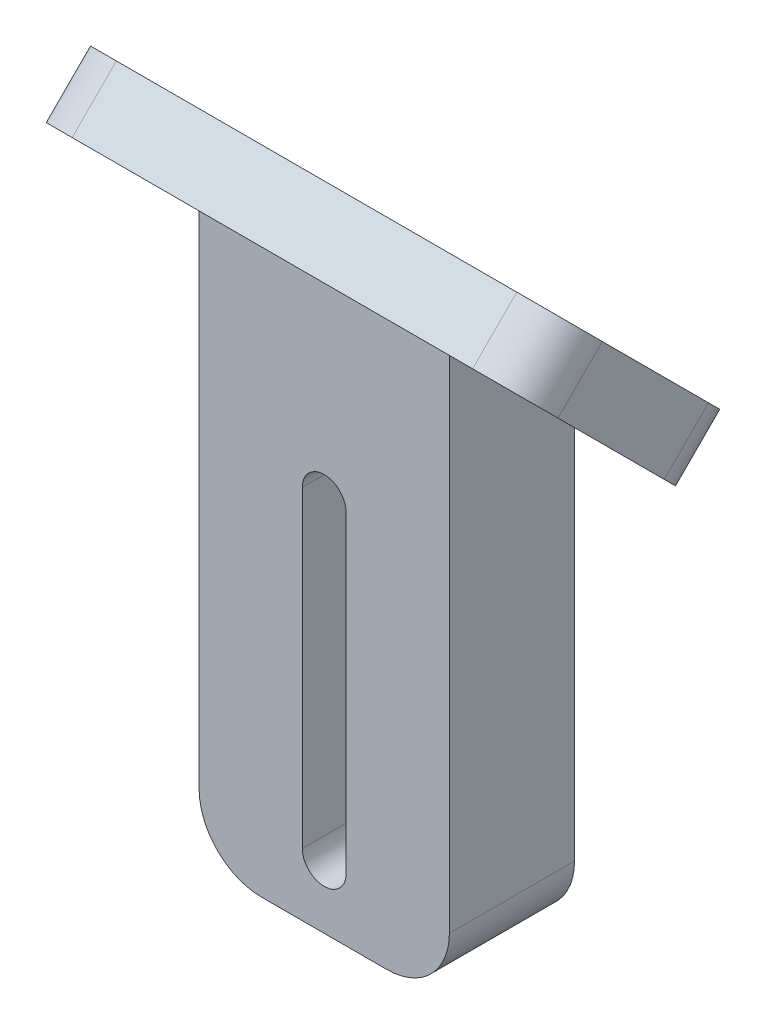
from build123d import *

# Parameters (mm, degrees)
BOSS_EXTRUDE1_DEPTH = 10
CUT_EXTRUDE1_DEPTH  = 11
FILLET1_R           = 5
SKETCH3_W           = 40
SKETCH3_H           = 20
BOSS_EXTRUDE2_DEPTH = 5
SKETCH4_R           = 1.75
CUT_EXTRUDE2_DEPTH  = 16
FILLET2_R           = 4


with BuildPart() as part:
    # Sketch1 → Boss-Extrude1 (new body, symmetric)
    with BuildSketch(Plane(origin=(0, 0, 0), x_dir=(0, 0, -1), z_dir=(1, 0, 0))):
        Polygon((0, 0), (0, -35), (-10, -35), (-10, 10), align=None)
    extrude(amount=BOSS_EXTRUDE1_DEPTH, both=True)

    # Sketch2 → Cut-Extrude1 (cut, through all)
    with BuildSketch(Plane.XY.offset(10)):
        with BuildLine():
            Line((1.75, -5), (1.75, -30))
            ThreePointArc((1.75, -30), (0, -31.75), (-1.75, -30))
            Line((-1.75, -30), (-1.75, -5))
            ThreePointArc((-1.75, -5), (0, -3.25), (1.75, -5))
        make_face()
    extrude(amount=-CUT_EXTRUDE1_DEPTH, mode=Mode.SUBTRACT)

    # Fillet1
    fillet1_edges = [part.edges().sort_by_distance(p)[0] for p in [
        (10, -35, 5),
        (-10, -35, 5),
    ]]
    fillet(fillet1_edges, radius=FILLET1_R)

    # Sketch3 → Boss-Extrude2 (add)
    with BuildSketch(Plane(origin=(0, 0, 0), x_dir=(1, 0, 0), z_dir=(0, 0.707106781, -0.707106781))):
        with Locations((0, -10)):
            Rectangle(SKETCH3_W, SKETCH3_H)
    extrude(amount=BOSS_EXTRUDE2_DEPTH)

    # Sketch4 → Cut-Extrude2 (cut, through all)
    with BuildSketch(Plane(origin=(0, 0, 0), x_dir=(1, 0, 0), z_dir=(0, -0.707106781, 0.707106781))):
        with Locations((-15, 10)):
            Circle(SKETCH4_R)
        with Locations((15, 10)):
            Circle(SKETCH4_R)
    extrude(amount=-CUT_EXTRUDE2_DEPTH, mode=Mode.SUBTRACT)

    # Fillet2
    fillet2_edges = [part.edges().sort_by_distance(p)[0] for p in [
        (-20, 1.767766953, -1.767766953),
        (-20, 15.909902577, 12.374368671),
        (20, 15.909902577, 12.374368671),
        (20, 1.767766953, -1.767766953),
    ]]
    fillet(fillet2_edges, radius=FILLET2_R)


solid = part.part
